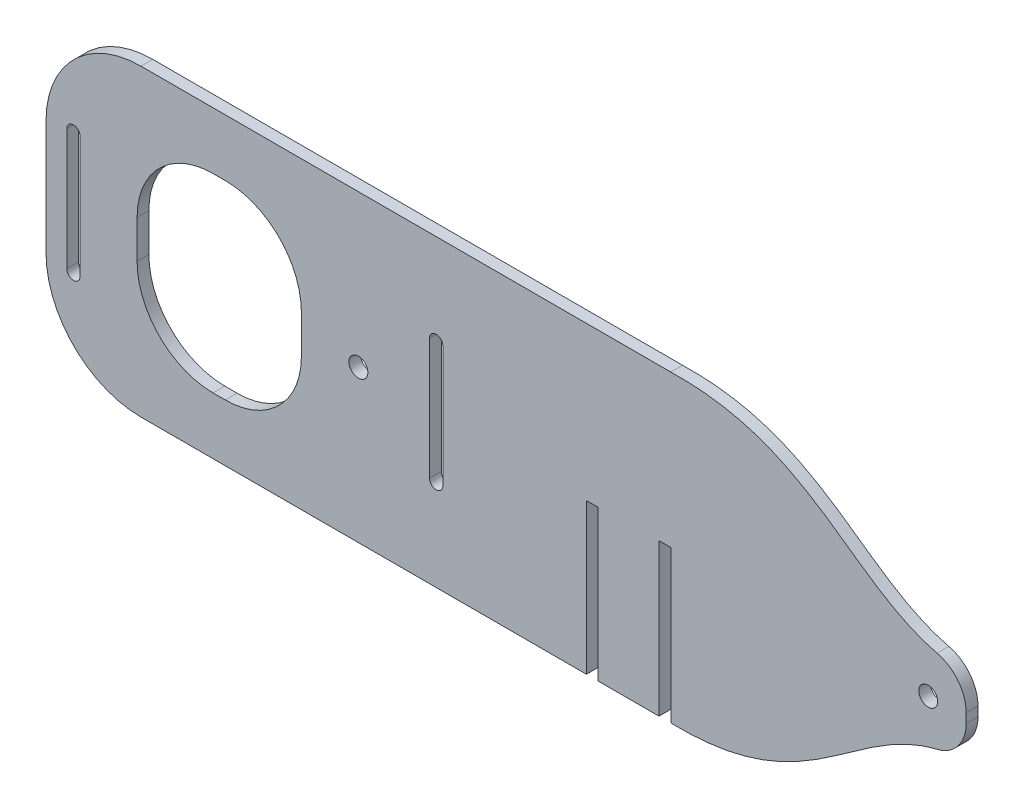
from build123d import *

# Parameters (mm, degrees)
SKETCH1_W           = 164.45
SKETCH1_H           = 80
SKETCH1_R           = 2.5
SKETCH1_W_2         = 43.25
SKETCH1_H_2         = 50
BOSS_EXTRUDE1_DEPTH = 3.1
SKETCH2_W           = 3.1
SKETCH2_H           = 39.596362368
SKETCH2_H_2         = 40
CUT_EXTRUDE1_DEPTH  = 4.1
FILLET1_R           = 25
SKETCH3_R           = 2.5
BOSS_EXTRUDE2_DEPTH = 3.1
FILLET3_R           = 10
FILLET4_R           = 20


with BuildPart() as part:
    # Sketch1 → Boss-Extrude1 (new body)
    with BuildSketch(Plane.XY):
        Rectangle(SKETCH1_W, SKETCH1_H)
        Circle(SKETCH1_R, mode=Mode.SUBTRACT)
        with BuildLine():
            Line((-76.75, -15.97), (-76.75, 15.97))
            ThreePointArc((-76.75, 15.97), (-75, 17.72), (-73.25, 15.97))
            Line((-73.25, 15.97), (-73.25, -15.97))
            ThreePointArc((-73.25, -15.97), (-75, -17.72), (-76.75, -15.97))
        make_face(mode=Mode.SUBTRACT)
        with BuildLine():
            Line((18.725, -15.97), (18.725, 15.97))
            ThreePointArc((18.725, 15.97), (20.475, 17.72), (22.225, 15.97))
            Line((22.225, 15.97), (22.225, -15.97))
            ThreePointArc((22.225, -15.97), (20.475, -17.72), (18.725, -15.97))
        make_face(mode=Mode.SUBTRACT)
        with Locations((-36.625, 0)):
            Rectangle(SKETCH1_W_2, SKETCH1_H_2, mode=Mode.SUBTRACT)
    extrude(amount=BOSS_EXTRUDE1_DEPTH)

    # Sketch2 → Cut-Extrude1 (cut, through all)
    with BuildSketch(Plane.XY.offset(3.1)):
        with Locations((61.575, -20.201818816)):
            Rectangle(SKETCH2_W, SKETCH2_H)
        with Locations((80.675, -20)):
            Rectangle(SKETCH2_W, SKETCH2_H_2)
    extrude(amount=-CUT_EXTRUDE1_DEPTH, mode=Mode.SUBTRACT)

    # Fillet1
    fillet1_edges = [part.edges().sort_by_distance(p)[0] for p in [
        (-82.225, -40, 1.55),
        (-82.225, 40, 1.55),
    ]]
    fillet(fillet1_edges, radius=FILLET1_R)

    # Sketch3 → Boss-Extrude2 (add)
    with BuildSketch(Plane.XY.offset(3.1)):
        with BuildLine():
            add(Edge.make_bspline(
                [(82.225, 40), (100.790922155, 40.44036534), (122.998075296, 29.670027282), (145.632337886, 10.163727788), (160, 10)],
                knots=[0, 0, 0, 0, 0.531248583, 1, 1, 1, 1], degree=3))
            Line((82.225, 40), (82.225, -40))
            add(Edge.make_bspline(
                [(82.225, -40), (100.790922155, -40.44036534), (122.998075296, -29.670027282), (145.632337886, -10.163727788), (160, -10)],
                knots=[0, 0, 0, 0, 0.531248583, 1, 1, 1, 1], degree=3))
            Line((160, -10), (160, 10))
        make_face()
        with Locations((150, 0)):
            Circle(SKETCH3_R, mode=Mode.SUBTRACT)
    extrude(amount=-BOSS_EXTRUDE2_DEPTH)

    # Fillet3
    fillet3_edges = [part.edges().sort_by_distance(p)[0] for p in [
        (160, -10, 1.55),
        (160, 10, 1.55),
    ]]
    fillet(fillet3_edges, radius=FILLET3_R)

    # Fillet4
    fillet4_edges = [part.edges().sort_by_distance(p)[0] for p in [
        (-15, -25, 1.55),
        (-15, 25, 1.55),
        (-58.25, 25, 1.55),
        (-58.25, -25, 1.55),
    ]]
    fillet(fillet4_edges, radius=FILLET4_R)


solid = part.part
